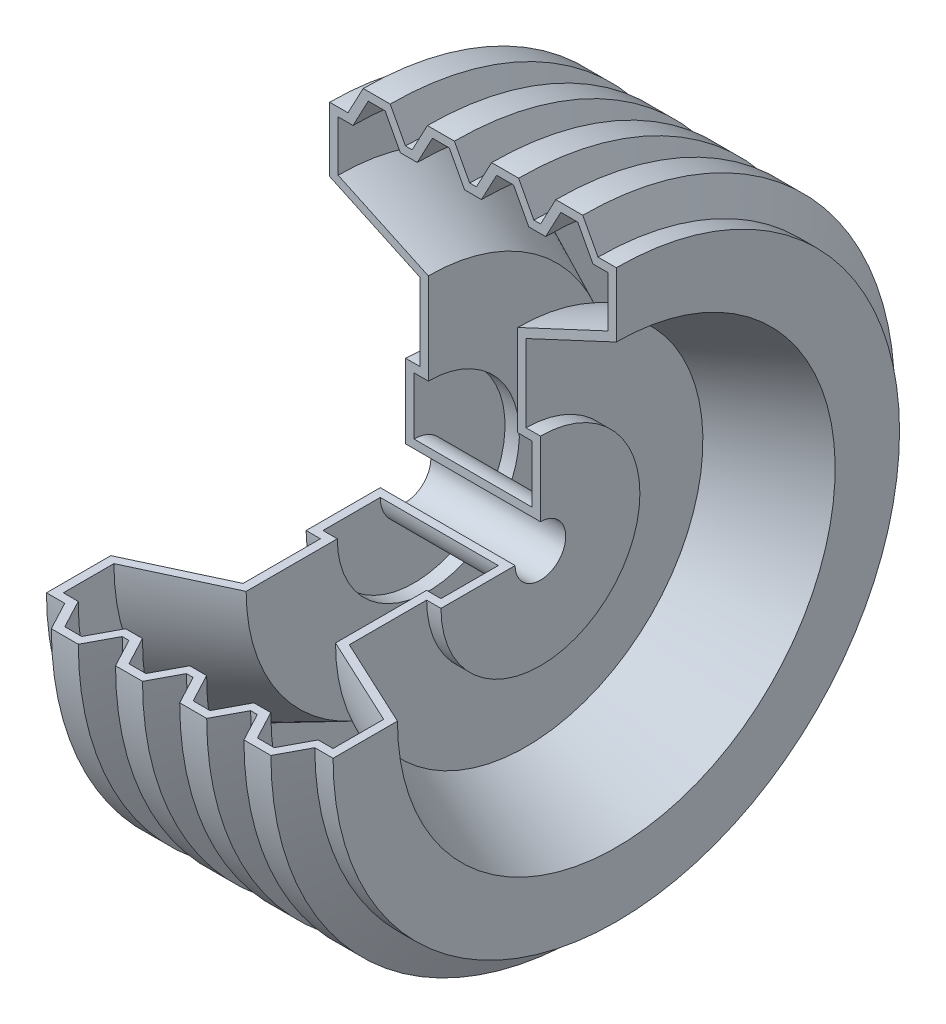
from build123d import *

# Parameters (mm, degrees)
REVOLVE_THIN1_ANGLE = 270


with BuildPart() as part:
    # Sketch2 → Revolve-Thin1 (revolve)
    with BuildSketch(Plane.XY):
        Polygon((-40, 15), (40, 15), (40, 59), (31.5, 59), (31.5, 104.867188985), (85, 129.814648696), (85, 168), (74.160544448, 168), (65.12148411, 185), (49.11287792, 185), (40.073817581, 168), (36.082423772, 168), (27.043363433, 185), (11.034757243, 185), (1.995696905, 168), (-1.995696905, 168), (-11.034757243, 185), (-27.043363433, 185), (-36.082423772, 168), (-40.073817581, 168), (-49.11287792, 185), (-65.12148411, 185), (-74.160544448, 168), (-85, 168), (-85, 129.814648696), (-31.5, 104.867188985), (-31.5, 59), (-40, 59), align=None)
        Polygon((-35, 20), (35, 20), (35, 54), (26.5, 54), (26.5, 108.052540289), (80, 133), (80, 163), (71.156241353, 163), (62.117181015, 180), (52.117181015, 180), (43.078120676, 163), (33.078120676, 163), (24.039060338, 180), (14.039060338, 180), (5, 163), (-5, 163), (-14.039060338, 180), (-24.039060338, 180), (-33.078120676, 163), (-43.078120676, 163), (-52.117181015, 180), (-62.117181015, 180), (-71.156241353, 163), (-80, 163), (-80, 133), (-26.5, 108.052540289), (-26.5, 54), (-35, 54), align=None, mode=Mode.SUBTRACT)
    revolve(axis=Axis((-156.924897256, 0, 0), (-1, 0, 0)), revolution_arc=REVOLVE_THIN1_ANGLE)


solid = part.part
